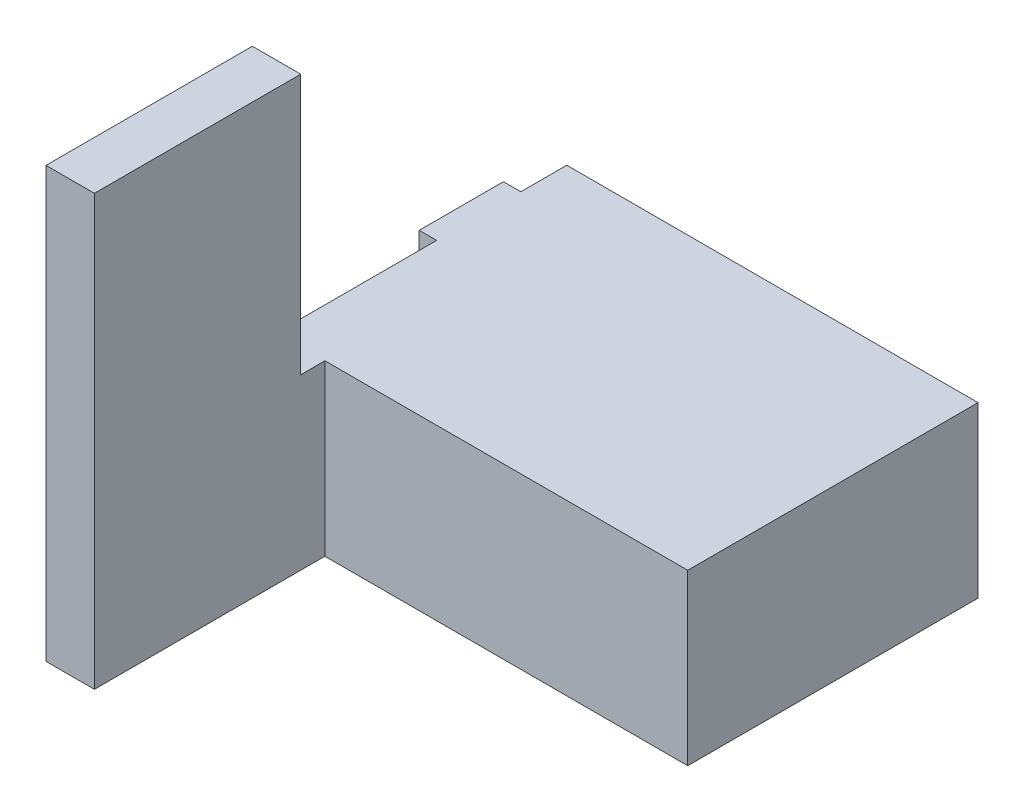
from build123d import *

# Parameters (mm, degrees)
BOSS_EXTRUDE2_DEPTH       = 88.9
SKETCH2_W                 = 25.4
SKETCH2_H                 = 108.331
BOSS_EXTRUDE3_DEPTH       = 136.652
M4X0_7_TAPPED_HOLE2_D     = 3.3
M4X0_7_TAPPED_HOLE2_DEPTH = 9.906
M4X0_7_TAPPED_HOLE2_TIP   = 0.991420021
SKETCH5_W                 = 44.196
SKETCH5_H                 = 44.196
BOSS_EXTRUDE4_DEPTH       = 9.144


with BuildPart() as part:
    # Sketch1 → Boss-Extrude2 (new body)
    with BuildSketch(Plane(origin=(0, 0, 0), x_dir=(1, 0, 0), z_dir=(0, 1, 0))):
        Polygon((-82.55, 86.075791262), (107.95, 86.075791262), (107.95, -66.324208738), (-82.55, -66.324208738), (-82.55, -187.355208738), (-107.95, -187.355208738), (-107.95, 86.075791262), align=None)
    extrude(amount=BOSS_EXTRUDE2_DEPTH)

    # Sketch2 → Boss-Extrude3 (add)
    with BuildSketch(Plane(origin=(0, 88.9, 0), x_dir=(1, 0, 0), z_dir=(0, 1, 0))):
        with Locations((-95.25, -133.189708738)):
            Rectangle(SKETCH2_W, SKETCH2_H)
    extrude(amount=BOSS_EXTRUDE3_DEPTH)

    # M4x0.7 Tapped Hole2
    with Locations(Plane(origin=(95.25, 0, -73.375791262), x_dir=(0, 0, -1), z_dir=(0, -1, 0))):
        with Locations((0, 0), (0, -192.024), (-127, -48.26), (-248.031, -192.024), (-165.1, -192.024)):
            Hole(M4X0_7_TAPPED_HOLE2_D / 2, depth=M4X0_7_TAPPED_HOLE2_DEPTH)
            with Locations((0, 0, -(M4X0_7_TAPPED_HOLE2_DEPTH + M4X0_7_TAPPED_HOLE2_TIP / 2))):  # 118° drill point
                Cone(0, M4X0_7_TAPPED_HOLE2_D / 2, M4X0_7_TAPPED_HOLE2_TIP, mode=Mode.SUBTRACT)

    # Sketch5 → Boss-Extrude4 (add)
    with BuildSketch(Plane.ZY.offset(107.95)):
        with Locations((-39.847791262, 66.802)):
            Rectangle(SKETCH5_W, SKETCH5_H)
    extrude(amount=BOSS_EXTRUDE4_DEPTH)


solid = part.part
